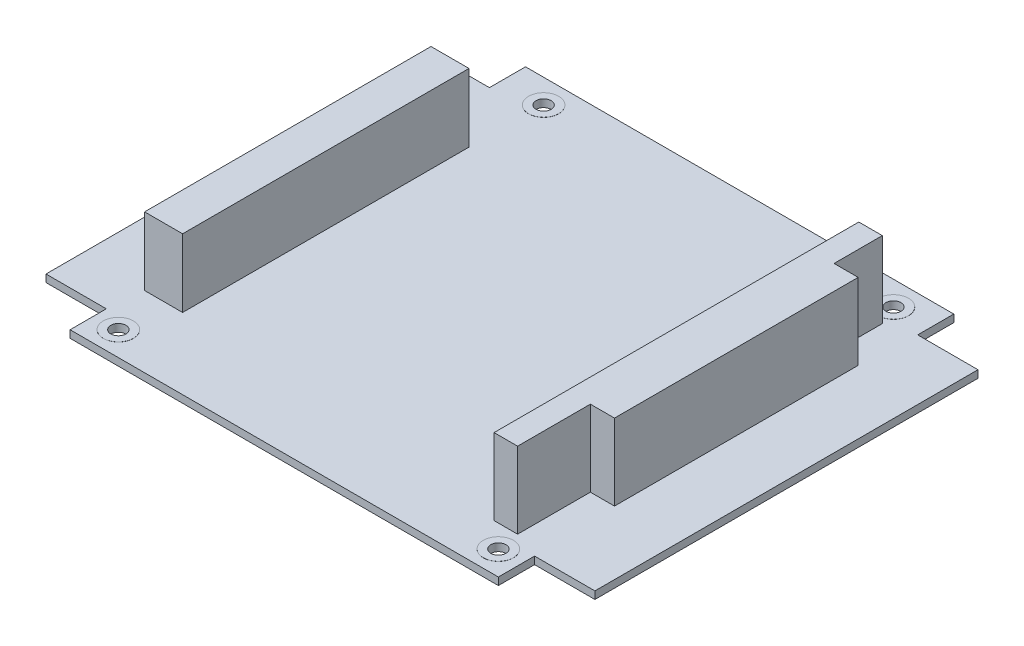
from build123d import *

# Parameters (mm, degrees)
BASE_EXTRUDE_DEPTH   = 1.57
SKETCH2_R            = 1.59
MOUNTING_HOLES_DEPTH = 76.101891787
SKETCH3_R            = 3.175
SKETCH3_R_2          = 1.59
TOP_PADS_DEPTH       = 0.02
SKETCH4_R            = 3.175
SKETCH4_R_2          = 1.59
BOTT_PADS_DEPTH      = 0.02
ISA_CNCT_DEPTH       = 16.05
SKETCH6_W            = 8
SKETCH6_H            = 60.3
PCI_CNCT_DEPTH       = 14.35


with BuildPart() as part:
    # Sketch1 → Base-Extrude (new body)
    with BuildSketch(Plane(origin=(0, 0, 0), x_dir=(1, 0, 0), z_dir=(0, 1, 0))):
        Polygon((-45.085, 47.945), (45.085, 47.945), (45.085, 40.343374485), (57.785, 40.343374485), (57.785, -40.318146652), (45.085, -40.318146652), (45.085, -47.945), (-45.085, -47.945), (-45.085, -40.318146652), (-57.785, -40.318146652), (-57.785, 40.343374485), (-45.085, 40.343374485), align=None)
    extrude(amount=BASE_EXTRUDE_DEPTH)

    # Sketch2 → Mounting Holes (cut, through all)
    with BuildSketch(Plane(origin=(0, 1.57, 0), x_dir=(-1, 0, 0), z_dir=(0, 1, 0))):
        with Locations(Location((36.195, -42.865, 0), (0, 0, 90))):
            Circle(SKETCH2_R)
        with Locations(Location((40.005, 42.865, 0), (0, 0, 90))):
            Circle(SKETCH2_R)
        with Locations(Location((-40.005, 42.865, 0), (0, 0, 90))):
            Circle(SKETCH2_R)
        with Locations(Location((-37.465, -42.865, 0), (0, 0, 90))):
            Circle(SKETCH2_R)
    extrude(amount=-MOUNTING_HOLES_DEPTH, mode=Mode.SUBTRACT)

    # Sketch3 → Top Pads (add)
    with BuildSketch(Plane(origin=(0, 1.57, 0), x_dir=(-1, 0, 0), z_dir=(0, 1, 0))):
        with Locations(Location((36.195, -42.865, 0), (0, 0, 270))):
            Circle(SKETCH3_R)
        with Locations(Location((36.195, -42.865, 0), (0, 0, 90))):
            Circle(SKETCH3_R_2, mode=Mode.SUBTRACT)
        with Locations(Location((-37.465, -42.865, 0), (0, 0, 270))):
            Circle(SKETCH3_R)
        with Locations(Location((-37.465, -42.865, 0), (0, 0, 90))):
            Circle(SKETCH3_R_2, mode=Mode.SUBTRACT)
        with Locations(Location((-40.005, 42.865, 0), (0, 0, 270))):
            Circle(SKETCH3_R)
        with Locations(Location((-40.005, 42.865, 0), (0, 0, 90))):
            Circle(SKETCH3_R_2, mode=Mode.SUBTRACT)
        with Locations(Location((40.005, 42.865, 0), (0, 0, 270))):
            Circle(SKETCH3_R)
        with Locations(Location((40.005, 42.865, 0), (0, 0, 90))):
            Circle(SKETCH3_R_2, mode=Mode.SUBTRACT)
    extrude(amount=TOP_PADS_DEPTH)

    # Sketch4 → Bott Pads (add)
    with BuildSketch(Plane.XZ):
        with Locations(Location((-36.195, -42.865, 0), (0, 0, 270))):
            Circle(SKETCH4_R)
        with Locations(Location((-36.195, -42.865, 0), (0, 0, 90))):
            Circle(SKETCH4_R_2, mode=Mode.SUBTRACT)
        with Locations(Location((37.465, -42.865, 0), (0, 0, 270))):
            Circle(SKETCH4_R)
        with Locations(Location((37.465, -42.865, 0), (0, 0, 90))):
            Circle(SKETCH4_R_2, mode=Mode.SUBTRACT)
        with Locations(Location((40.005, 42.865, 0), (0, 0, 270))):
            Circle(SKETCH4_R)
        with Locations(Location((40.005, 42.865, 0), (0, 0, 90))):
            Circle(SKETCH4_R_2, mode=Mode.SUBTRACT)
        with Locations(Location((-40.005, 42.865, 0), (0, 0, 270))):
            Circle(SKETCH4_R)
        with Locations(Location((-40.005, 42.865, 0), (0, 0, 90))):
            Circle(SKETCH4_R_2, mode=Mode.SUBTRACT)
    extrude(amount=BOTT_PADS_DEPTH)

    # Sketch5 → ISA Cnct (add)
    with BuildSketch(Plane(origin=(0, 1.57, 0), x_dir=(-1, 0, 0), z_dir=(0, 1, 0))):
        Polygon((-39.305, 22.795), (-39.305, 38.115), (-34.355, 38.115), (-34.355, -38.675), (-39.305, -38.675), (-39.305, -28.515), (-44.385, -28.515), (-44.385, 22.795), align=None)
    extrude(amount=ISA_CNCT_DEPTH)

    # Sketch6 → PCI Cnct (add)
    with BuildSketch(Plane(origin=(0, 1.57, 0), x_dir=(-1, 0, 0), z_dir=(0, 1, 0))):
        with Locations((40.385, 2.805)):
            Rectangle(SKETCH6_W, SKETCH6_H)
    extrude(amount=PCI_CNCT_DEPTH)


solid = part.part
